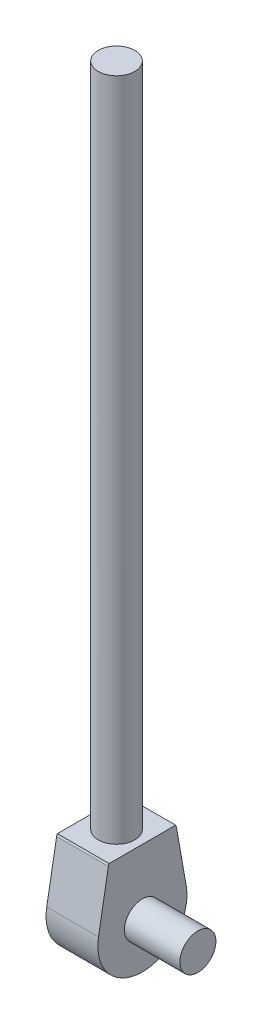
from build123d import *

# Parameters (mm, degrees)
EXTRUDE1_DEPTH      = 28.448
EXTRUDE1_DEPTH_BACK = 28.448
SKETCH7_R           = 20.066
EXTRUDE2_DEPTH      = 731.393
SKETCH8_R           = 34.173782646
EXTRUDE3_DEPTH      = 60.96
SKETCH9_R           = 19.812
EXTRUDE4_DEPTH      = 60.96


with BuildPart() as part:
    # Sketch6 → Extrude1 (new, two sides: drawn at the far end of the back side and taken through both)
    with BuildSketch(Plane(origin=(0, 0, 0), x_dir=(0, 0, -1), z_dir=(1, 0, 0)).offset(-EXTRUDE1_DEPTH_BACK)):
        with BuildLine():
            Line((36.538920518, 71.697598607), (-36.538913711, 71.697596168))
            ThreePointArc((-36.538913711, 71.697596168), (-37.054496025, 70.591976021), (-37.3703, 69.41363444))
            Line((-37.3703, 69.41363444), (-48.25031, 7.73618444))
            ThreePointArc((-48.25031, 7.73618444), (5e-06, -49.77053593), (48.25032, 7.73618444))
            Line((48.25032, 7.73618444), (37.37031, 69.41363444))
            ThreePointArc((37.37031, 69.41363444), (37.054505048, 70.591977567), (36.538920518, 71.697598607))
        make_face()
    extrude(amount=EXTRUDE1_DEPTH + EXTRUDE1_DEPTH_BACK)

    # Sketch7 → Extrude2 (add)
    with BuildSketch(Plane(origin=(0, 71.697597388, 2.392e-06), x_dir=(-1, 0, 0), z_dir=(0, 0.9999999999999996, 3.33665997890797e-08))):
        Circle(SKETCH7_R)
    extrude(amount=EXTRUDE2_DEPTH)

    # Sketch8 → Extrude3 (add)
    with BuildSketch(Plane(origin=(28.448, 0, 0), x_dir=(0, 0, -1), z_dir=(1, 0, 0))):
        Circle(SKETCH8_R)
    extrude(amount=-EXTRUDE3_DEPTH)

    # Sketch9 → Extrude4 (add)
    with BuildSketch(Plane(origin=(28.448, 0, 0), x_dir=(0, 0, -1), z_dir=(1, 0, 0))):
        Circle(SKETCH9_R)
    extrude(amount=EXTRUDE4_DEPTH)


solid = part.part
